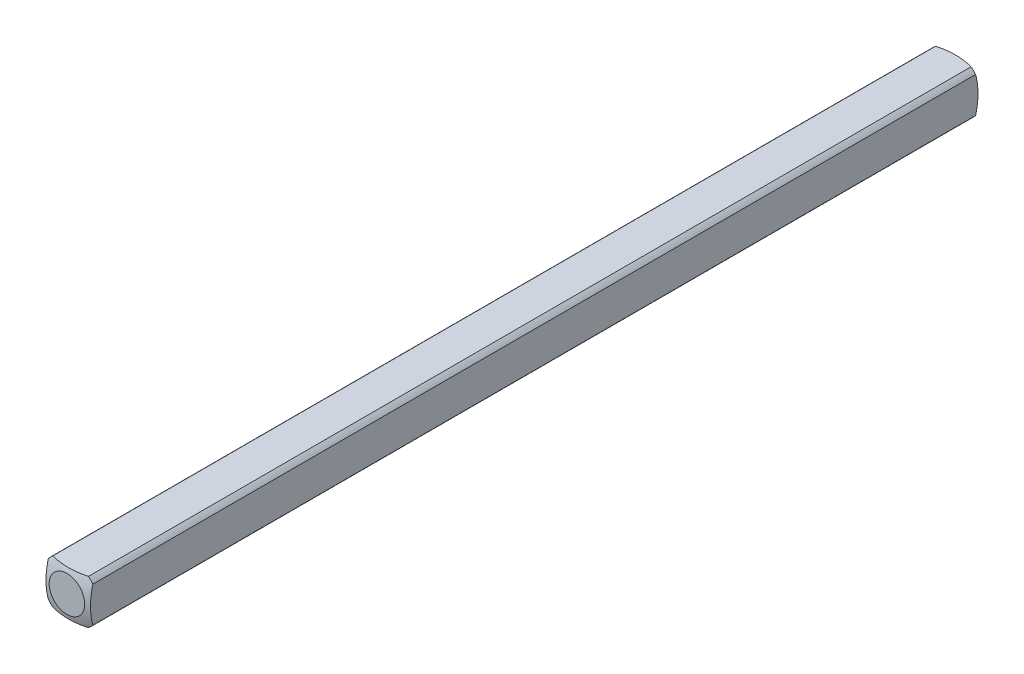
from build123d import *

# Parameters (mm, degrees)
SKETCH1_W           = 3.175
SKETCH1_H           = 3.175
BOSS_EXTRUDE1_DEPTH = 31.75
SKETCH2_OUTSIDE_W   = 11.588
SKETCH2_OUTSIDE_H   = 11.589
SKETCH2_OUTSIDE_R   = 2.032
CUT_EXTRUDE1_DEPTH  = 32.75


with BuildPart() as part:
    # Sketch1 → Boss-Extrude1 (new body)
    with BuildSketch(Plane.XY):
        Rectangle(SKETCH1_W, SKETCH1_H)
    extrude(amount=BOSS_EXTRUDE1_DEPTH)

    # Sketch2 outside → Cut-Extrude1 (cut, through all)
    with BuildSketch(Plane(origin=(0, 0, 0), x_dir=(-1, 0, 0), z_dir=(0, 0, -1))):
        with Locations((0, -0.0005)):
            Rectangle(SKETCH2_OUTSIDE_W, SKETCH2_OUTSIDE_H)
        Circle(SKETCH2_OUTSIDE_R, mode=Mode.SUBTRACT)
    extrude(amount=-CUT_EXTRUDE1_DEPTH, mode=Mode.SUBTRACT)

    # Sketch3 → Cut-Revolve1 (revolve, cut)
    with BuildSketch(Plane(origin=(0, 0, 0), x_dir=(1, 0, 0), z_dir=(0, 1, 0))):
        with BuildLine():
            Line((-5.053685963, -4.40273269), (-5.053685963, 5.740530545))
            Line((-5.053685963, 5.740530545), (0, 5.740530545))
            Line((0, 5.740530545), (0, 0.160877736))
            ThreePointArc((0, 0.160877736), (-3.404639553, -1.148866368), (-5.053685963, -4.40273269))
        make_face()
    revolve(axis=Axis((0, 0, 31.75), (0, 0, -1)), mode=Mode.SUBTRACT)

    # Mirror1: part across plane


with BuildPart() as part_1:
    add(part.part)
    add(part.part.mirror(Plane(origin=(0, 0, 31.75), x_dir=(1, 0, 0), z_dir=(0, 0, -1))))


solid = part_1.part
